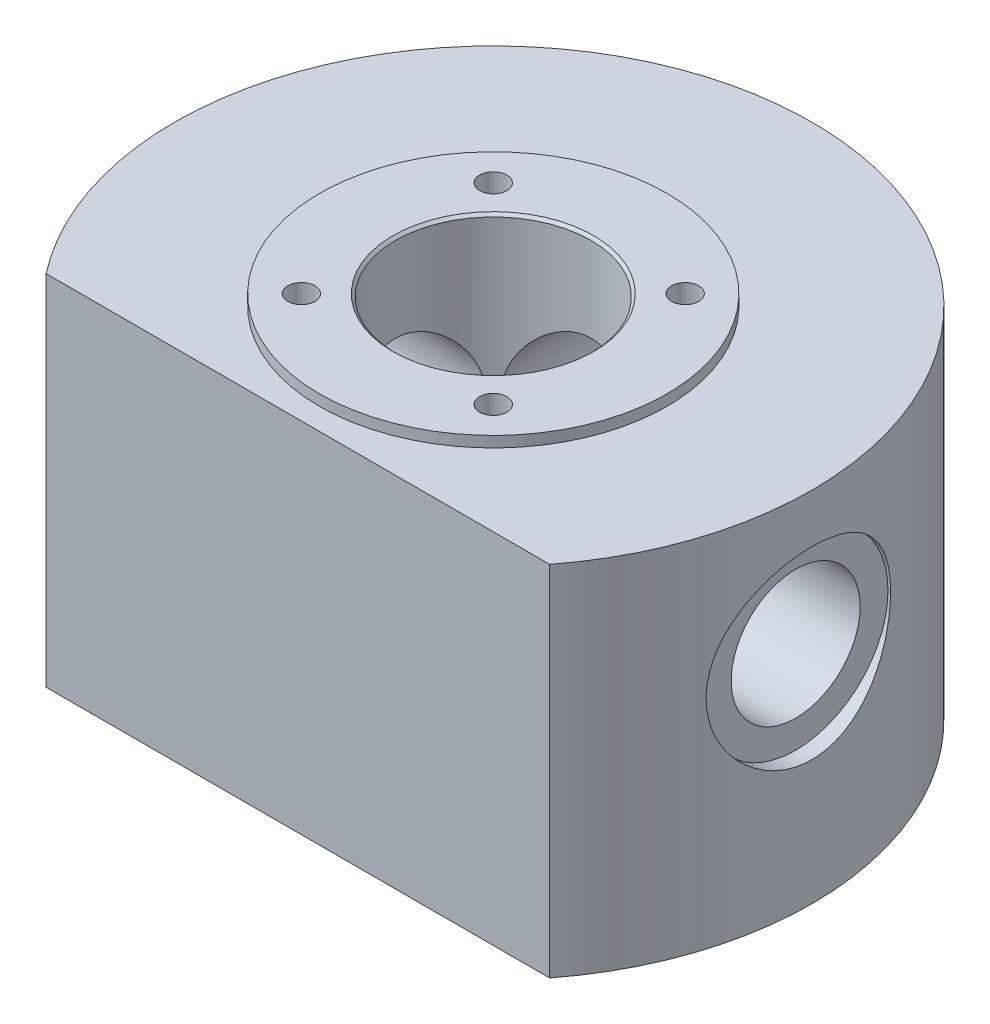
from build123d import *

# Parameters (mm, degrees)
ESBO_O4_W                           = 5.9436
ESBO_O4_H                           = 29.356
FURO_ROSCADO_DE_1_4_18_NPSM3_REACH  = 70.621
FURO_ROSCADO_DE_1_4_18_NPSM3_BORE_R = 5.9436
ESBO_O12_R                          = 16
ESBO_O12_R_2                        = 9
RESSALTO_EXTRUS_O1_DEPTH            = 1
PADR_OCIRCULAR5_COUNT               = 4
CHANFRO1_SIZE                       = 0.5
CHANFRO2_SIZE                       = 0.25
FURO_ROSCADO_DE_1_4_18_NPSM2_D      = 11.8872
ESBO_O18_R                          = 8.5
CORTE_EXTRUS_O4_DEPTH               = 1.5
ESBO_O20_R                          = 8.5
CORTE_EXTRUS_O5_DEPTH               = 1.5
CORTE_EXTRUS_O6_DEPTH               = 54.033475186


with BuildPart() as part:
    # Esboço1 → Revolução1 (revolve)
    with BuildSketch(Plane.XY, mode=Mode.PRIVATE) as revolu_o1_sk:
        Polygon((0, -20), (29.356, -20), (29.356, 13), (9, 13), (9, -13), (3, -13), (3, -17.6), (0, -17.6), align=None)
    revolve(revolu_o1_sk.sketch.rotate(Axis((0, -20, 0), (0, 1, 0)), 90), axis=Axis((0, -20, 0), (0, 1, 0)))

    # Esboço4 → Furo roscado de 1_4-18 NPSM1 (revolve, cut)
    with BuildSketch(Plane(origin=(29.356, 0, 0), x_dir=(0, 0, -1), z_dir=(0, 1, 0))):
        with Locations((2.9718, 14.678)):
            Rectangle(ESBO_O4_W, ESBO_O4_H)
    revolve(axis=Axis((35.706, 0, 0), (-1, 0, 0)), mode=Mode.SUBTRACT)

    # Furo roscado de 1_4-18 NPSM3 bore → Furo roscado de 1_4-18 NPSM3 (cut, up to next)
    with BuildSketch(Plane(origin=(0, 0, -29.356), x_dir=(0, -1, 0), z_dir=(0, 0, -1)), mode=Mode.PRIVATE) as furo_roscado_de_1_4_18_npsm3_sk1:
        Circle(FURO_ROSCADO_DE_1_4_18_NPSM3_BORE_R)
    furo_roscado_de_1_4_18_npsm3_tool1 = extrude(furo_roscado_de_1_4_18_npsm3_sk1.sketch, amount=-FURO_ROSCADO_DE_1_4_18_NPSM3_REACH, mode=Mode.PRIVATE) & part.part
    add(furo_roscado_de_1_4_18_npsm3_tool1.solids().sort_by_distance((0, 0, -29.356))[0], mode=Mode.SUBTRACT)

    # Esboço12 → Ressalto-extrusão1 (add)
    with BuildSketch(Plane(origin=(0, 13, 0), x_dir=(1, 0, 0), z_dir=(0, 1, 0))):
        with Locations(Location((0, 0, 0), (0, 0, 270))):
            Circle(ESBO_O12_R)
        with Locations(Location((0, 0, 0), (0, 0, 90))):
            Circle(ESBO_O12_R_2, mode=Mode.SUBTRACT)
    extrude(amount=RESSALTO_EXTRUS_O1_DEPTH)

    # Esboço13 → Furo roscado de M3x0.51 (revolve, cut)
    with BuildSketch(Plane(origin=(8.838834765, 14, -8.838834765), x_dir=(0, 0, 1), z_dir=(1, 0, 0))):
        Polygon((0, 0), (0, 10.751075774), (1.25, 10), (1.25, 0), align=None)
    furo_roscado_de_m3x0_51 = revolve(axis=Axis((8.838834765, 20.35, -8.838834765), (0, -1, 0)), mode=Mode.SUBTRACT)

    # PadrãoCircular5: Furo roscado de M3x0.51 ×4 about axis
    padr_ocircular5_axis = Axis((0, 0, 0), (0, 1, 0))
    for i in range(1, PADR_OCIRCULAR5_COUNT):
        add(furo_roscado_de_m3x0_51.rotate(padr_ocircular5_axis, i * 360 / PADR_OCIRCULAR5_COUNT), mode=Mode.SUBTRACT)

    # Chanfro1
    chanfro1_edges = [part.edges().sort_by_distance(p)[0] for p in [
        (0, -13, 3),
    ]]
    chamfer(chanfro1_edges, length=CHANFRO1_SIZE)

    # Chanfro2
    chanfro2_edges = [part.edges().sort_by_distance(p)[0] for p in [
        (0, 14, 9),
    ]]
    chamfer(chanfro2_edges, length=CHANFRO2_SIZE)

    # Furo roscado de 1_4-18 NPSM2 (through all)
    with Locations(Plane(origin=(-29.356, 0, 0), x_dir=(0, 0, -1), z_dir=(-1, 0, 0))):
        with Locations((0, 0)):
            Hole(FURO_ROSCADO_DE_1_4_18_NPSM2_D / 2)

    # Esboço18 → Corte-extrusão4 (cut)
    with BuildSketch(Plane(origin=(-29.356, 0, 0), x_dir=(0, -1, 0), z_dir=(-1, 0, 0))):
        with Locations(Location((0, 0, 0), (0, 0, 90))):
            Circle(ESBO_O18_R)
    corte_extrus_o4 = extrude(amount=-CORTE_EXTRUS_O4_DEPTH, mode=Mode.SUBTRACT)

    # Esboço20 → Corte-extrusão5 (cut)
    with BuildSketch(Plane(origin=(0, 0, -29.356), x_dir=(0, -1, 0), z_dir=(0, 0, 1))):
        Circle(ESBO_O20_R)
    extrude(amount=CORTE_EXTRUS_O5_DEPTH, mode=Mode.SUBTRACT)

    # Espelhar1: Corte-extrusão4 across plane
    add(corte_extrus_o4.mirror(Plane(origin=(0, 0, 0), x_dir=(0, 0, 1), z_dir=(1, 0, 0))), mode=Mode.SUBTRACT)

    # Esboço21 → Corte-extrusão6 (cut, through all)
    with BuildSketch(Plane(origin=(0, 13, 0), x_dir=(1, 0, 0), z_dir=(0, 1, 0))):
        with BuildLine():
            Line((-23.189970591, -18), (23.189970591, -18))
            ThreePointArc((23.189970591, -18), (0, -29.356), (-23.189970591, -18))
        make_face()
    extrude(amount=-CORTE_EXTRUS_O6_DEPTH, mode=Mode.SUBTRACT)


solid = part.part
